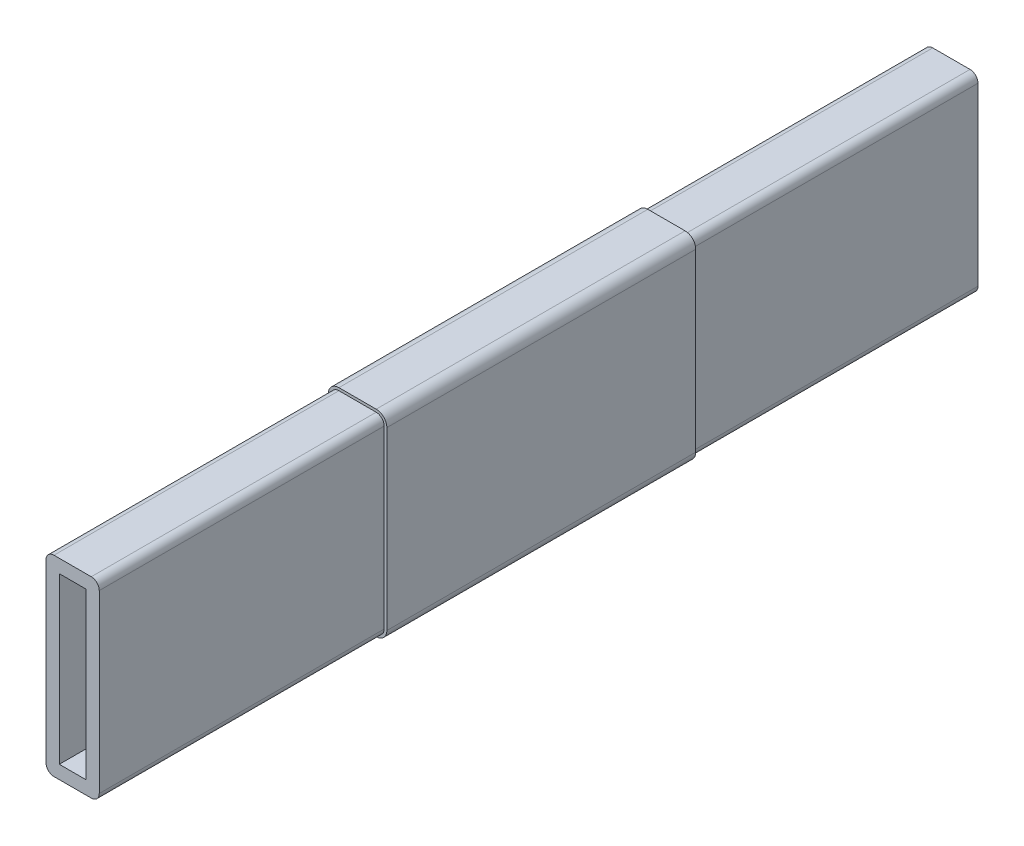
from build123d import *

# Parameters (mm, degrees)
SKETCH1_W               = 22
SKETCH1_H               = 74
BOSS_EXTRUDE1_DEPTH     = 330
SKETCH4_W               = 10
SKETCH4_H               = 62
CUT_EXTRUDE2_DEPTH      = 1
CUT_EXTRUDE2_DEPTH_BACK = 331
SKETCH6_W               = 22
SKETCH6_H               = 74
SKETCH6_W_2             = 20
SKETCH6_H_2             = 72
CUT_EXTRUDE4_DEPTH      = 107
SKETCH7_W               = 22
SKETCH7_H               = 74
SKETCH7_W_2             = 20
SKETCH7_H_2             = 72
CUT_EXTRUDE5_DEPTH      = 107
FILLET1_R               = 3
FILLET2_R               = 4


with BuildPart() as part:
    # Sketch1 → Boss-Extrude1 (new body)
    with BuildSketch(Plane.XY):
        Rectangle(SKETCH1_W, SKETCH1_H)
    extrude(amount=BOSS_EXTRUDE1_DEPTH)

    # Sketch4 → Cut-Extrude2 (cut, two sides)
    with BuildSketch(Plane.XY.offset(330)) as cut_extrude2_sk:
        Rectangle(SKETCH4_W, SKETCH4_H)
    extrude(amount=CUT_EXTRUDE2_DEPTH, mode=Mode.SUBTRACT)
    extrude(cut_extrude2_sk.sketch, amount=-CUT_EXTRUDE2_DEPTH_BACK, mode=Mode.SUBTRACT)

    # Sketch6 → Cut-Extrude4 (cut)
    with BuildSketch(Plane.XY.offset(330)):
        Rectangle(SKETCH6_W, SKETCH6_H)
        Rectangle(SKETCH6_W_2, SKETCH6_H_2, mode=Mode.SUBTRACT)
    extrude(amount=-CUT_EXTRUDE4_DEPTH, mode=Mode.SUBTRACT)

    # Sketch7 → Cut-Extrude5 (cut)
    with BuildSketch(Plane(origin=(0, 0, 0), x_dir=(-1, 0, 0), z_dir=(0, 0, -1))):
        Rectangle(SKETCH7_W, SKETCH7_H)
        Rectangle(SKETCH7_W_2, SKETCH7_H_2, mode=Mode.SUBTRACT)
    extrude(amount=-CUT_EXTRUDE5_DEPTH, mode=Mode.SUBTRACT)

    # Fillet1
    fillet1_edges = [part.edges().sort_by_distance(p)[0] for p in [
        (10, -36, 276.5),
        (-10, -36, 276.5),
        (-10, 36, 276.5),
        (10, 36, 276.5),
        (-10, -36, 53.5),
        (10, -36, 53.5),
        (10, 36, 53.5),
        (-10, 36, 53.5),
    ]]
    fillet(fillet1_edges, radius=FILLET1_R)

    # Fillet2
    fillet2_edges = [part.edges().sort_by_distance(p)[0] for p in [
        (11, -37, 165),
        (-11, -37, 165),
        (-11, 37, 165),
        (11, 37, 165),
    ]]
    fillet(fillet2_edges, radius=FILLET2_R)


solid = part.part
